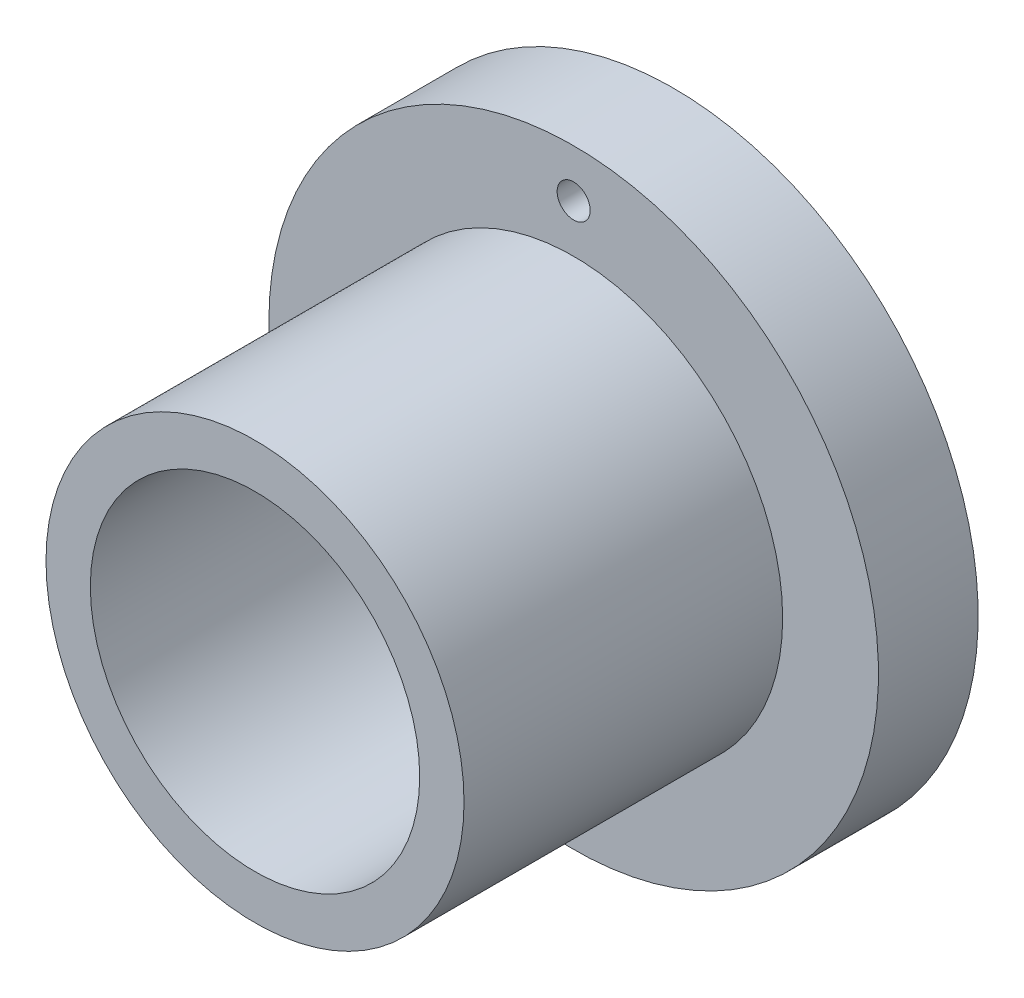
from build123d import *

# Parameters (mm, degrees)
F_0_80_TAPPED_HOLE1_D = 1.19126


with BuildPart() as part:
    # Sketch1 → Revolve1 (revolve)
    with BuildSketch(Plane(origin=(0, 0, 0), x_dir=(0, 0, -1), z_dir=(1, 0, 0)), mode=Mode.PRIVATE) as revolve1_sk:
        Polygon((15.1, 11), (15.1, 7.5436), (13, 7.5436), (13, 5.9436), (0, 5.9436), (0, 7.5436), (11.5, 7.5436), (11.5, 11), align=None)
    revolve(revolve1_sk.sketch.rotate(Axis((0, 0, 0), (0, 0, 1)), 90), axis=Axis((0, 0, 0), (0, 0, 1)))  # turned: the seam where the file's is

    # #0-80 Tapped Hole1 (through all)
    with Locations(Plane(origin=(0, 0, -15.1), x_dir=(-1, 0, 0), z_dir=(0, 0, -1))):
        with Locations((0, 9.2718)):
            f_0_80_tapped_hole1 = Hole(F_0_80_TAPPED_HOLE1_D / 2)

    # Mirror1: #0-80 Tapped Hole1 across plane
    add(f_0_80_tapped_hole1.mirror(Plane.ZX), mode=Mode.SUBTRACT)


solid = part.part
